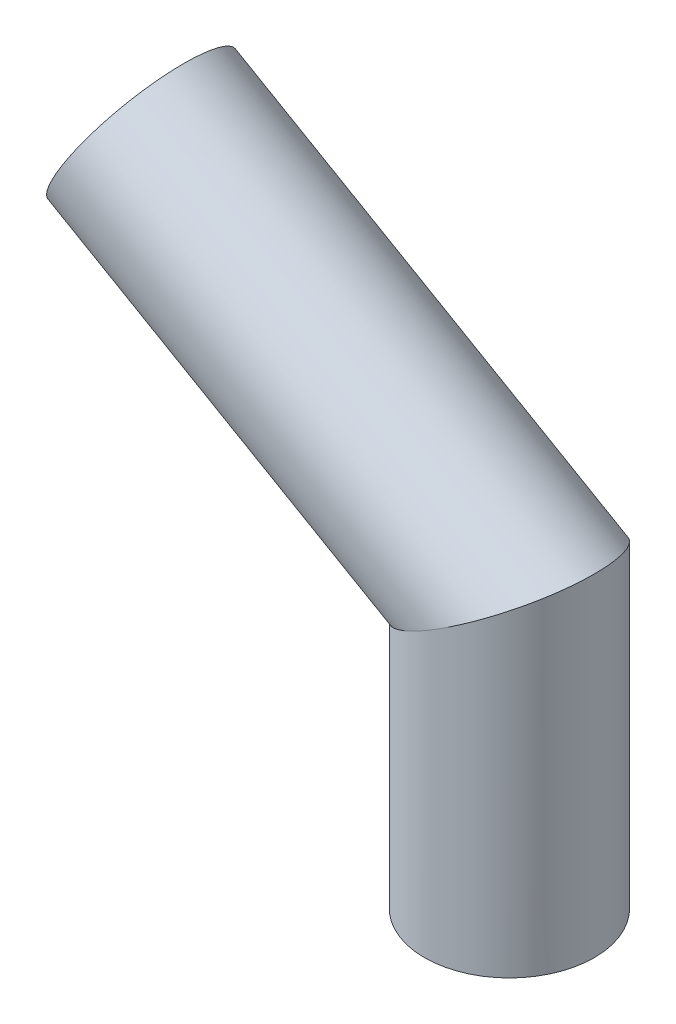
from build123d import *

# Parameters (mm, degrees)
SKETCH6_R = 299.977316584


with BuildPart() as part:
    # Sweep2: sweep along a path in Sketch5
    with BuildLine(Plane.XY) as sweep2_path:
        Line((0, 0), (1299.038105677, -750))
        Line((1299.038105677, -750), (1299.038105677, -1750))
    # Sketch6 → Sweep2 (sweep)
    with BuildSketch(Plane(origin=(0, -1750, 0), x_dir=(1, 0, 0), z_dir=(0, 1, 0))):
        with Locations((1299.038105677, 0)):
            Circle(SKETCH6_R)
    sweep(path=sweep2_path.line, transition=Transition.RIGHT)


solid = part.part
